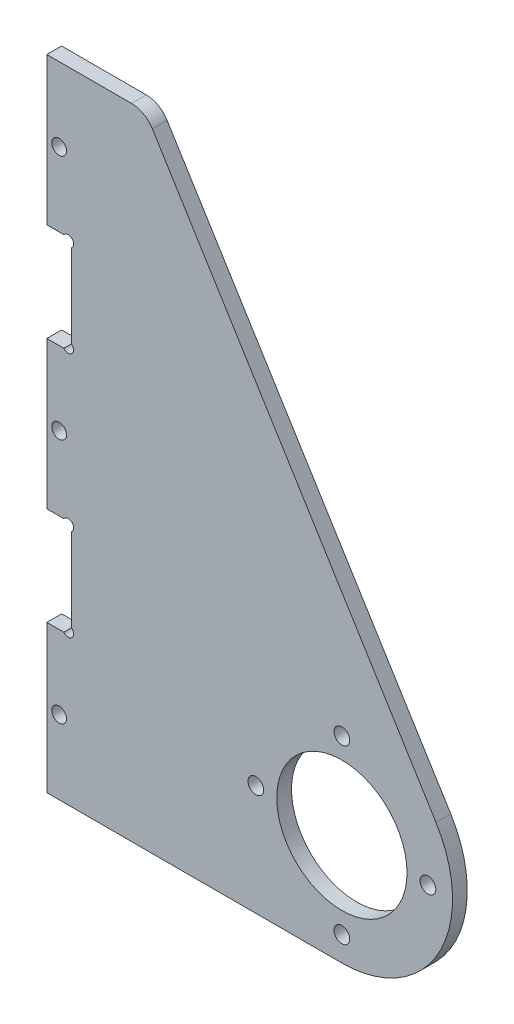
from build123d import *

# Parameters (mm, degrees)
SKETCH_2_R          = 13.25
SKETCH_2_R_2        = 1.6
EXTRUDE_1_DEPTH     = 3
FILLET_3_R          = 5
SKETCH_4_R          = 1.5
SKETCH_4_R_2        = 1.1
SKETCH_4_W          = 5
SKETCH_4_H          = 20
CUT_EXTRUDE_1_DEPTH = 10


with BuildPart() as part:
    # ｽｹｯﾁ2 → ﾎﾞｽ - 押し出し1 (new body)
    with BuildSketch(Plane.XY):
        with BuildLine():
            Line((-60, -22.5), (-40, -22.5))
            Line((-40, -22.5), (0, -22.5))
            ThreePointArc((0, -22.5), (19.65247344, -10.9558335), (19.138597944, 11.830641096))
            Line((19.138597944, 11.830641096), (-40, 107.5))
            Line((-40, 107.5), (-60, 107.5))
            Line((-60, 107.5), (-60, -22.5))
        make_face()
        Circle(SKETCH_2_R, mode=Mode.SUBTRACT)
        with Locations((0, 17.5)):
            Circle(SKETCH_2_R_2, mode=Mode.SUBTRACT)
        with Locations((17.5, 0)):
            Circle(SKETCH_2_R_2, mode=Mode.SUBTRACT)
        with Locations((0, -17.5)):
            Circle(SKETCH_2_R_2, mode=Mode.SUBTRACT)
        with Locations((-17.5, 0)):
            Circle(SKETCH_2_R_2, mode=Mode.SUBTRACT)
    extrude(amount=EXTRUDE_1_DEPTH)

    # ﾌｨﾚｯﾄ3
    fillet_3_edges = [part.edges().sort_by_distance(p)[0] for p in [
        (-40, 107.5, 1.5),
    ]]
    fillet(fillet_3_edges, radius=FILLET_3_R)

    # ｽｹｯﾁ4 → ｶｯﾄ - 押し出し1 (cut)
    with BuildSketch(Plane.XY.offset(3)):
        with Locations((-57.5, -7.5)):
            Circle(SKETCH_4_R)
        with Locations((-57.5, 42.5)):
            Circle(SKETCH_4_R)
        with Locations((-57.5, 92.5)):
            Circle(SKETCH_4_R)
        with Locations((-55.66, 26.84)):
            Circle(SKETCH_4_R_2)
        with Locations((-55.66, 8.16)):
            Circle(SKETCH_4_R_2)
        with Locations((-55.66, 58.16)):
            Circle(SKETCH_4_R_2)
        with Locations((-55.66, 76.84)):
            Circle(SKETCH_4_R_2)
        with Locations((-57.5, 67.5)):
            Rectangle(SKETCH_4_W, SKETCH_4_H)
        with Locations((-57.5, 17.5)):
            Rectangle(SKETCH_4_W, SKETCH_4_H)
    extrude(amount=-CUT_EXTRUDE_1_DEPTH, mode=Mode.SUBTRACT)


solid = part.part
